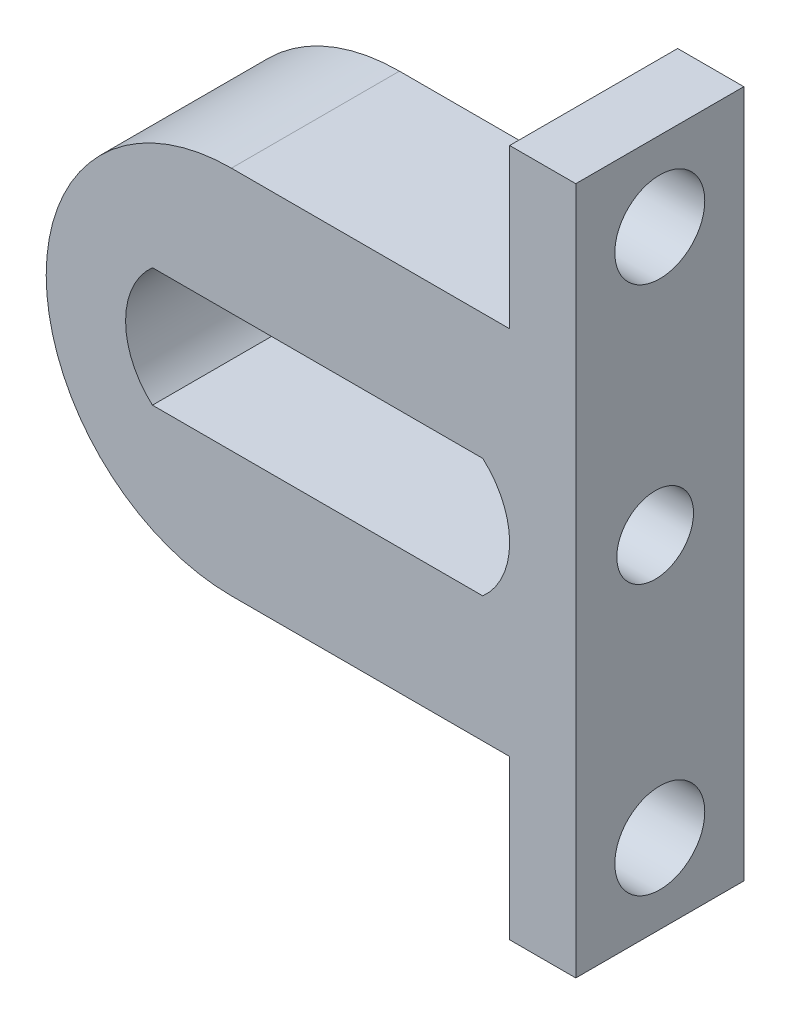
from build123d import *

# Parameters (mm, degrees)
BOSS_EXTRUDE1_DEPTH = 6.35
CUT_EXTRUDE1_REACH  = 22.016
SKETCH2_R           = 1.7
SKETCH2_R_2         = 1.45


with BuildPart() as part:
    # Sketch1 → Boss-Extrude1 (new body)
    with BuildSketch(Plane.XY):
        with BuildLine():
            Line((515.21, 42.790633073), (512.71, 42.790633073))
            Line((512.71, 42.790633073), (512.71, 48.790633073))
            Line((512.71, 48.790633073), (502.194313483, 48.790633073))
            ThreePointArc((502.194313483, 48.790633073), (495.194313483, 55.790633073), (502.194313483, 62.790633073))
            Line((502.194313483, 62.790633073), (512.71, 62.790633073))
            Line((512.71, 62.790633073), (512.71, 68.790633073))
            Line((512.71, 68.790633073), (515.21, 68.790633073))
            Line((515.21, 68.790633073), (515.21, 42.790633073))
        make_face()
        with BuildLine():
            Line((511.694313483, 53.540633073), (499.21, 53.540633073))
            ThreePointArc((499.21, 53.540633073), (498.194313483, 55.790633073), (499.21, 58.040633073))
            Line((499.21, 58.040633073), (511.694313483, 58.040633073))
            ThreePointArc((511.694313483, 58.040633073), (512.71, 55.790633073), (511.694313483, 53.540633073))
        make_face(mode=Mode.SUBTRACT)
    extrude(amount=BOSS_EXTRUDE1_DEPTH)

    # Sketch2 → Cut-Extrude1 (cut, up to next)
    with BuildSketch(Plane(origin=(515.21, 0, 0), x_dir=(0, 0, -1), z_dir=(1, 0, 0)), mode=Mode.PRIVATE) as cut_extrude1_sk1:
        with Locations((-3.175, 45.790633073)):
            Circle(SKETCH2_R)
    cut_extrude1_tool1 = extrude(cut_extrude1_sk1.sketch, amount=-CUT_EXTRUDE1_REACH, mode=Mode.PRIVATE) & part.part
    add(cut_extrude1_tool1.solids().sort_by_distance((515.21, 45.790633, 3.175))[0], mode=Mode.SUBTRACT)
    # Sketch2 → Cut-Extrude1 (cut, up to next)
    with BuildSketch(Plane(origin=(515.21, 0, 0), x_dir=(0, 0, -1), z_dir=(1, 0, 0)), mode=Mode.PRIVATE) as cut_extrude1_sk2:
        with Locations((-3.35, 55.790633073)):
            Circle(SKETCH2_R_2)
    cut_extrude1_tool2 = extrude(cut_extrude1_sk2.sketch, amount=-CUT_EXTRUDE1_REACH, mode=Mode.PRIVATE) & part.part
    add(cut_extrude1_tool2.solids().sort_by_distance((515.21, 55.790633, 3.35))[0], mode=Mode.SUBTRACT)
    # Sketch2 → Cut-Extrude1 (cut, up to next)
    with BuildSketch(Plane(origin=(515.21, 0, 0), x_dir=(0, 0, -1), z_dir=(1, 0, 0)), mode=Mode.PRIVATE) as cut_extrude1_sk3:
        with Locations((-3.175, 65.790633073)):
            Circle(SKETCH2_R)
    cut_extrude1_tool3 = extrude(cut_extrude1_sk3.sketch, amount=-CUT_EXTRUDE1_REACH, mode=Mode.PRIVATE) & part.part
    add(cut_extrude1_tool3.solids().sort_by_distance((515.21, 65.790633, 3.175))[0], mode=Mode.SUBTRACT)


solid = part.part
